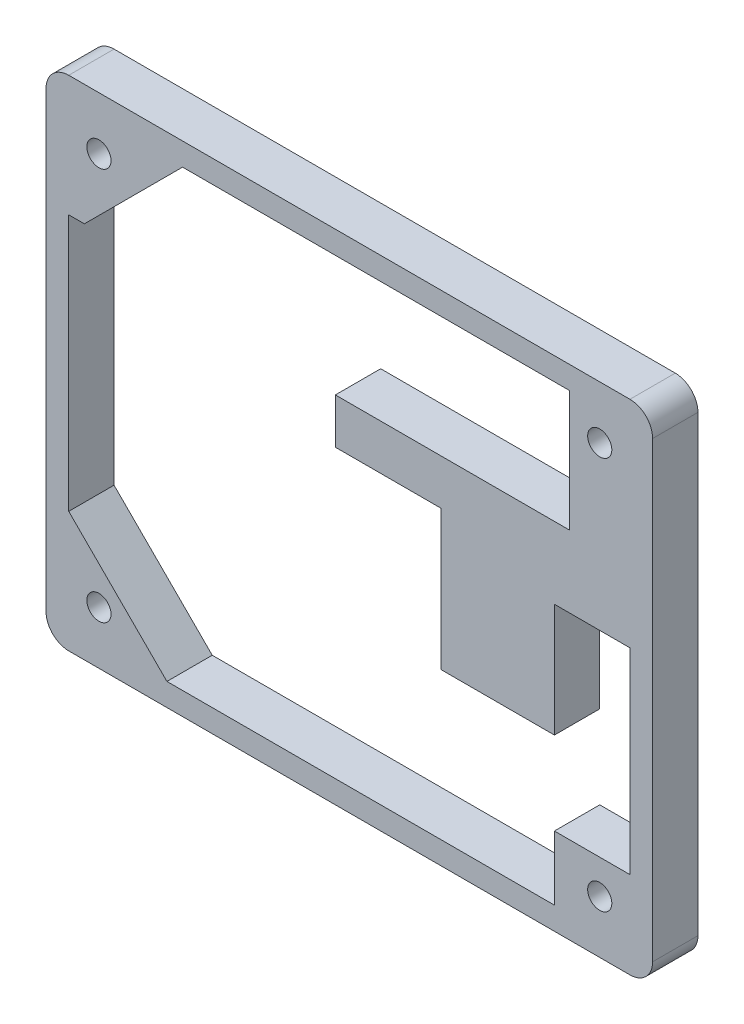
from build123d import *

# Parameters (mm, degrees)
SKETCH1_W                  = 80.3
SKETCH1_H                  = 66
BOSS_EXTRUDE1_DEPTH        = 6
F_3_2_3_2_DIAMETER_HOLE1_D = 3.2
FILLET1_R                  = 3
SKETCH4_W                  = 19
SKETCH4_H                  = 34
SKETCH4_W_2                = 31
SKETCH4_H_2                = 16
SKETCH4_W_3                = 7
SKETCH4_H_3                = 7
SKETCH4_W_4                = 13
SKETCH4_H_4                = 17
SKETCH4_W_5                = 40
SKETCH4_H_5                = 19.5
SKETCH4_W_6                = 10
SKETCH4_H_6                = 26
CUT_EXTRUDE1_DEPTH         = 7
CUT_EXTRUDE3_DEPTH         = 7


with BuildPart() as part:
    # Sketch1 → Boss-Extrude1 (new body)
    with BuildSketch(Plane.XY):
        with Locations((40.15, 33)):
            Rectangle(SKETCH1_W, SKETCH1_H)
    extrude(amount=BOSS_EXTRUDE1_DEPTH)

    # Ø3.2 (3.2) Diameter Hole1 (through all)
    with Locations(Plane.XY.offset(6)):
        with Locations((7, 59), (73.3, 59), (73.3, 7), (7, 7)):
            Hole(F_3_2_3_2_DIAMETER_HOLE1_D / 2)

    # Fillet1
    fillet1_edges = [part.edges().sort_by_distance(p)[0] for p in [
        (0, 66, 3),
        (80.3, 66, 3),
        (80.3, 0, 3),
        (0, 0, 3),
    ]]
    fillet(fillet1_edges, radius=FILLET1_R)

    # Sketch4 → Cut-Extrude1 (cut, through all)
    with BuildSketch(Plane.XY.offset(6)):
        with Locations((12.5, 33)):
            Rectangle(SKETCH4_W, SKETCH4_H)
        with Locations((53.8, 55)):
            Rectangle(SKETCH4_W_2, SKETCH4_H_2)
        with Locations((31.5, 53)):
            Rectangle(SKETCH4_W_3, SKETCH4_H_3)
        with Locations((45.8, 32.5)):
            Rectangle(SKETCH4_W_4, SKETCH4_H_4)
        with Locations((45.829355907, 12.75)):
            Rectangle(SKETCH4_W_5, SKETCH4_H_5)
        with Locations((72.3, 24.5)):
            Rectangle(SKETCH4_W_6, SKETCH4_H_6)
    extrude(amount=-CUT_EXTRUDE1_DEPTH, mode=Mode.SUBTRACT)

    # Sketch5 → Cut-Extrude3 (cut, through all)
    with BuildSketch(Plane.XY.offset(6)):
        Polygon((67.3, 11.5), (67.3, 3), (16, 3), (3, 16), (3, 50), (5.071067812, 50), (18.071067812, 63), (38.3, 63), (69.3, 63), (69.3, 47), (38.3, 47), (38.3, 41), (52.3, 41), (52.3, 22.5), (67.3, 22.5), align=None)
    extrude(amount=-CUT_EXTRUDE3_DEPTH, mode=Mode.SUBTRACT)


solid = part.part
